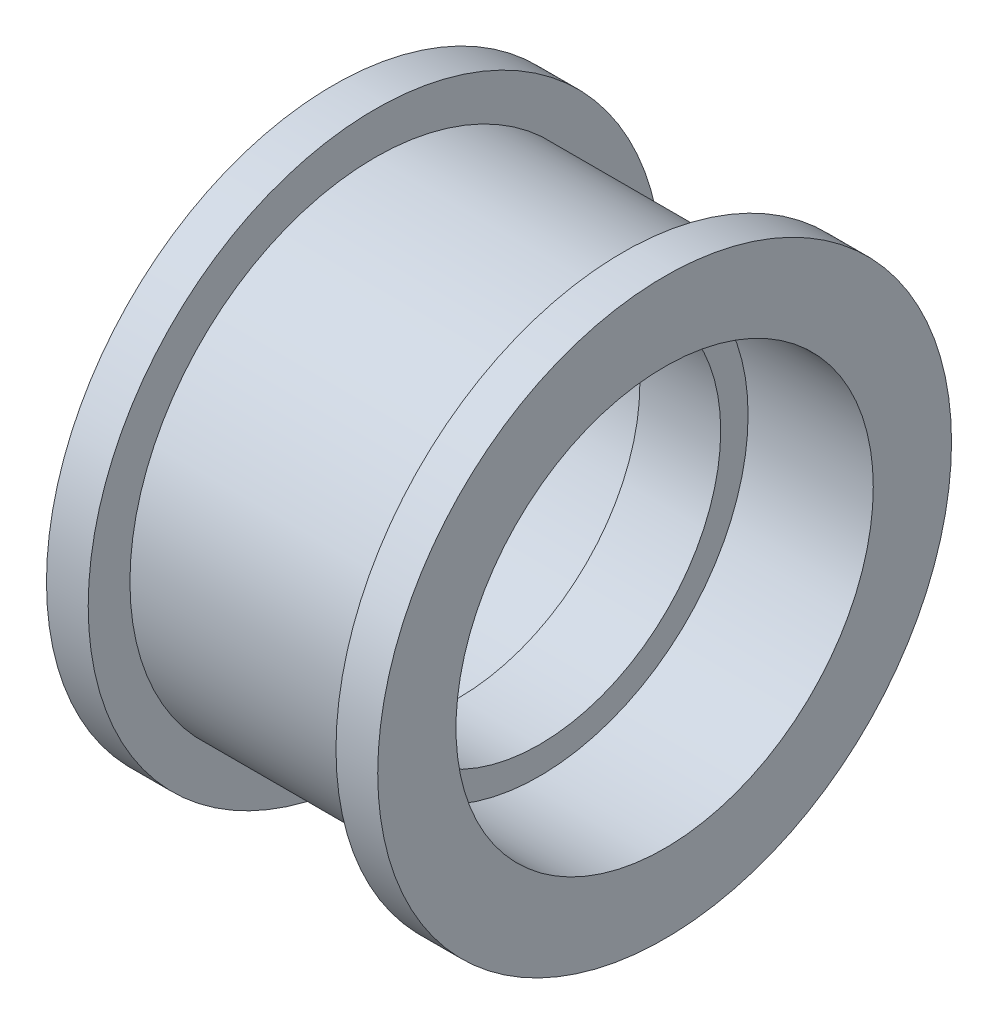
from build123d import *


with BuildPart() as part:
    # Sketch1 → Revolve1 (revolve)
    with BuildSketch(Plane.XY):
        Polygon((1.55, 6.95), (-1.55, 6.95), (-1.55, 8), (-6.35, 8), (-6.35, 11), (-4.75, 11), (-4.75, 9.4), (4.75, 9.4), (4.75, 11), (6.35, 11), (6.35, 8), (1.55, 8), align=None)
    revolve(axis=Axis((0, 0, 0), (-1, 0, 0)))


solid = part.part
